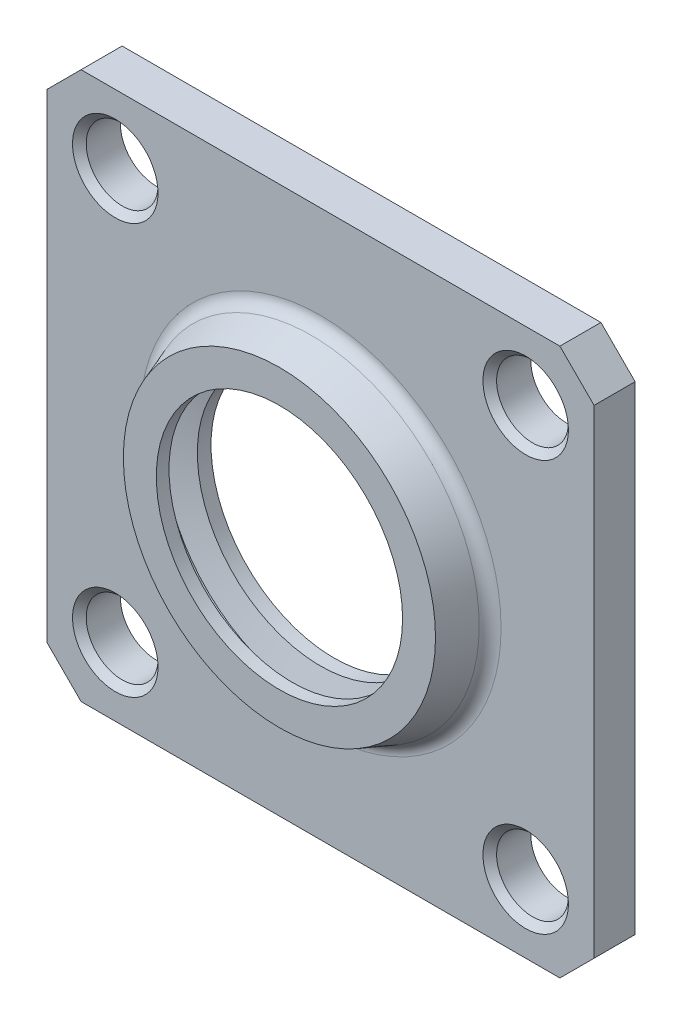
from build123d import *

# Parameters (mm, degrees)
SKETCH1_W                        = 80
SKETCH1_H                        = 80
BOSS_EXTRUDE1_DEPTH              = 6
F_10_5_10_5_DIAMETER_HOLE1_D     = 10.5
F_10_5_10_5_DIAMETER_HOLE1_DEPTH = 6
CHAMFER1_SIZE                    = 5
CHAMFER2_SIZE                    = 1
FILLET1_R                        = 1
FILLET2_R                        = 2
SCALE1_SCALE                     = 0.75


with BuildPart() as part:
    # Sketch1 → Boss-Extrude1 (new body)
    with BuildSketch(Plane.XY.offset(6)):
        Rectangle(SKETCH1_W, SKETCH1_H)
    extrude(amount=-BOSS_EXTRUDE1_DEPTH)

    # Sketch2 → Revolve1 (revolve)
    with BuildSketch(Plane(origin=(0, 0, 0), x_dir=(1, 0, 0), z_dir=(0, 1, 0))):
        Polygon((25, -6), (0, -6), (0, -12), (22.816178594, -12), align=None)
    revolve(axis=Axis((0, 0, 6), (0, 0, 1)))

    # Sketch3 → Cut-Revolve1 (revolve, cut)
    with BuildSketch(Plane(origin=(0, 0, 0), x_dir=(1, 0, 0), z_dir=(0, 1, 0))):
        Polygon((26, 0), (0, 0), (0, -12), (18, -12), (18, -10.143593539), (22, -9.07179677), (22, -7.07179677), (18, -6), (18, -4), (26, -4), align=None)
    revolve(axis=Axis((0, 0, 0), (0, 0, 1)), mode=Mode.SUBTRACT)

    # Ø10.5 (10.5) Diameter Hole1
    with Locations(Plane.XY.offset(6)):
        with Locations((30, 30), (-30, 30), (-30, -30), (30, -30)):
            Hole(F_10_5_10_5_DIAMETER_HOLE1_D / 2, depth=F_10_5_10_5_DIAMETER_HOLE1_DEPTH)

    # Chamfer1
    chamfer1_edges = [part.edges().sort_by_distance(p)[0] for p in [
        (-40, -40, 3),
        (-40, 40, 3),
        (40, 40, 3),
        (40, -40, 3),
    ]]
    chamfer(chamfer1_edges, length=CHAMFER1_SIZE)

    # Chamfer2
    chamfer2_edges = [part.edges().sort_by_distance(p)[0] for p in [
        (-26, 0, 0),
        (35.25, -30, 6),
        (-24.75, -30, 6),
        (-24.75, 30, 6),
        (35.25, 30, 6),
    ]]
    chamfer(chamfer2_edges, length=CHAMFER2_SIZE)

    # Fillet1
    fillet1_edges = [part.edges().sort_by_distance(p)[0] for p in [
        (-26, 0, 4),
    ]]
    fillet(fillet1_edges, radius=FILLET1_R)

    # Fillet2
    fillet2_edges = [part.edges().sort_by_distance(p)[0] for p in [
        (-25, 0, 6),
    ]]
    fillet(fillet2_edges, radius=FILLET2_R)


with BuildPart() as part_1:
    # Scale1: scaled about (0, 0, 3.839535201)
    add(part.part.scale(SCALE1_SCALE).moved(Location((0, 0, 0.9598838))))


solid = part_1.part
